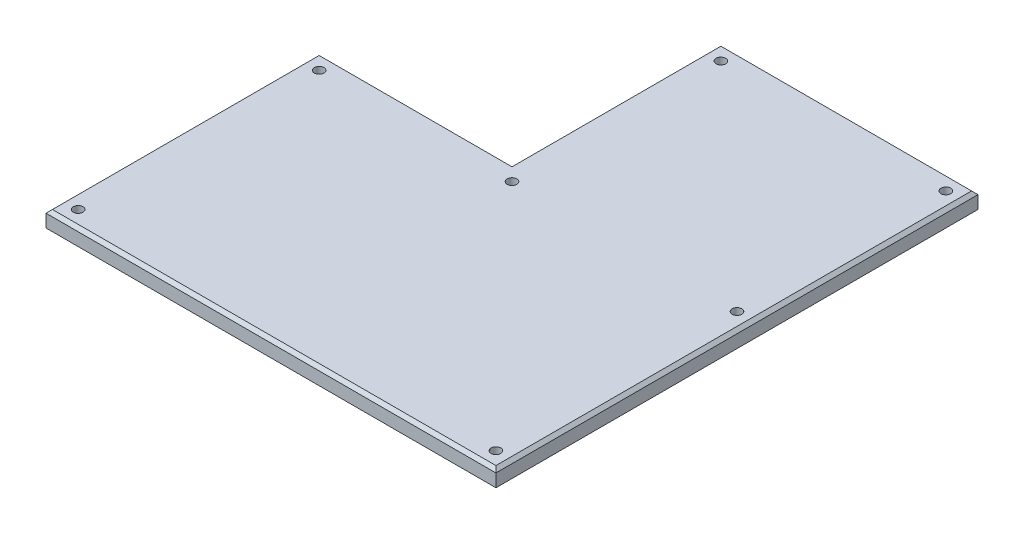
from build123d import *

# Parameters (mm, degrees)
BOSS_EXTRUDE1_DEPTH  = 5
CHAMFER1_SIZE        = 1
SKETCH2_R            = 1.5
CUT_EXTRUDE1_DEPTH   = 5
LPATTERN1_COUNT      = 2
LPATTERN1_PITCH      = 130
LPATTERN1_COUNT_DIR2 = 2
LPATTERN1_PITCH_DIR2 = 75
SKETCH3_R            = 1.5
CUT_EXTRUDE2_DEPTH   = 5
LPATTERN2_COUNT      = 2
LPATTERN2_PITCH      = 70
LPATTERN3_COUNT      = 2
LPATTERN3_PITCH      = 65


with BuildPart() as part:
    # Sketch1 → Boss-Extrude1 (new body)
    with BuildSketch(Plane(origin=(0, 0, 0), x_dir=(1, 0, 0), z_dir=(0, 1, 0))):
        Polygon((140, 150), (140, 0), (0, 0), (0, 85), (60, 85), (60, 150), align=None)
    extrude(amount=BOSS_EXTRUDE1_DEPTH)

    # Chamfer1
    chamfer1_edges = [part.edges().sort_by_distance(p)[0] for p in [
        (140, 5, -75),
        (100, 5, -150),
        (60, 5, -117.5),
        (30, 5, -85),
        (0, 5, -42.5),
        (70, 5, 0),
    ]]
    chamfer(chamfer1_edges, length=CHAMFER1_SIZE)

    # Sketch2 → Cut-Extrude1 (cut)
    with BuildSketch(Plane(origin=(0, 5, 0), x_dir=(1, 0, 0), z_dir=(0, 1, 0))):
        with Locations((5, 80)):
            Circle(SKETCH2_R)
    cut_extrude1 = extrude(amount=-CUT_EXTRUDE1_DEPTH, mode=Mode.SUBTRACT)

    # LPattern1: Cut-Extrude1 2 × 2
    with Locations(*[(i * LPATTERN1_PITCH, 0, j * LPATTERN1_PITCH_DIR2) for i in range(LPATTERN1_COUNT) for j in range(LPATTERN1_COUNT_DIR2) if (i, j) != (0, 0)]):
        add(cut_extrude1, mode=Mode.SUBTRACT)

    # Sketch3 → Cut-Extrude2 (cut)
    with BuildSketch(Plane(origin=(0, 5, 0), x_dir=(1, 0, 0), z_dir=(0, 1, 0))):
        with Locations((65, 145)):
            Circle(SKETCH3_R)
    cut_extrude2 = extrude(amount=-CUT_EXTRUDE2_DEPTH, mode=Mode.SUBTRACT)

    # LPattern2: Cut-Extrude2 ×2
    with Locations(*[(i * LPATTERN2_PITCH, 0, 0) for i in range(1, LPATTERN2_COUNT)]):
        add(cut_extrude2, mode=Mode.SUBTRACT)

    # LPattern3: Cut-Extrude2 ×2
    with Locations(*[(0, 0, i * LPATTERN3_PITCH) for i in range(1, LPATTERN3_COUNT)]):
        add(cut_extrude2, mode=Mode.SUBTRACT)


solid = part.part
